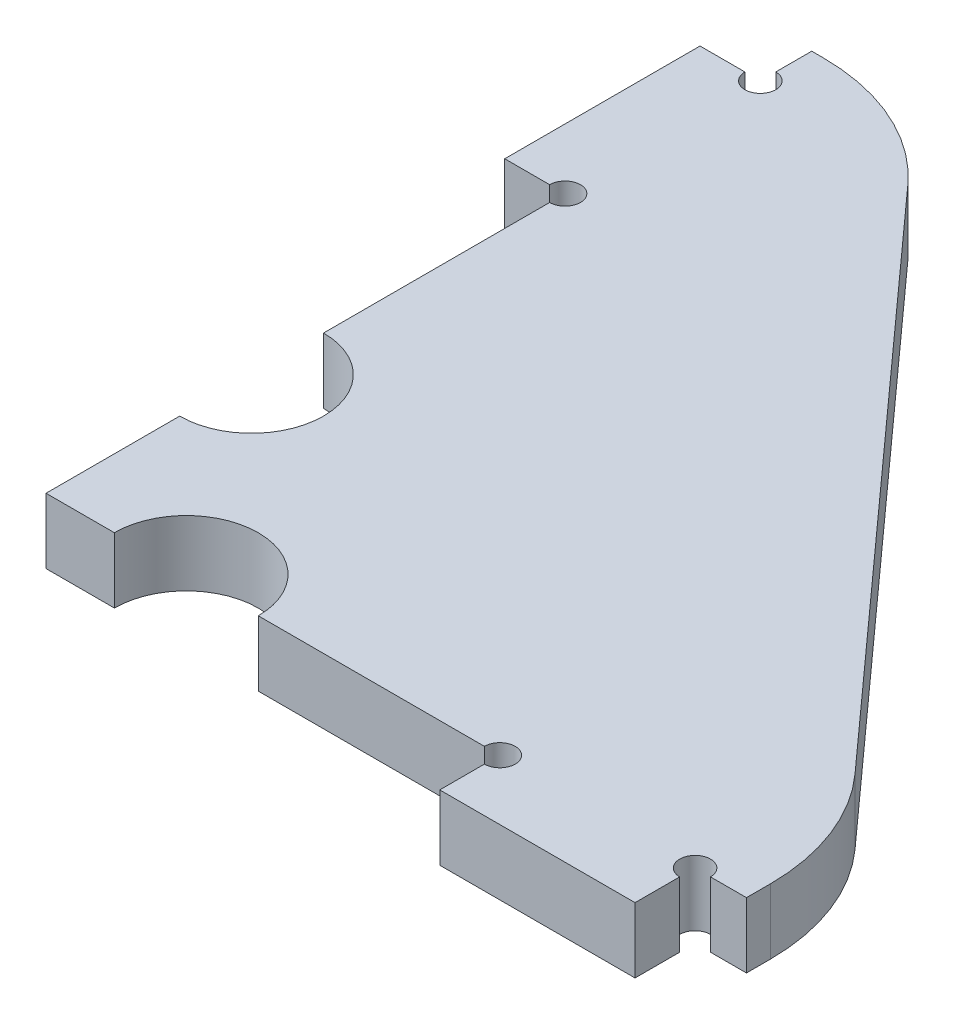
from build123d import *

# Parameters (mm, degrees)
BOSS_EXTRUDE1_DEPTH = 6.35
SKETCH3_R           = 1.5
SKETCH3_R_2         = 7
CUT_EXTRUDE1_DEPTH  = 7.35
FILLET1_R           = 20


with BuildPart() as part:
    # Sketch2 → Boss-Extrude1 (new body)
    with BuildSketch(Plane(origin=(0, 0, 0), x_dir=(1, 0, 0), z_dir=(0, 1, 0))):
        Polygon((0, 0), (44.15, 0), (44.15, -5.842), (63.15, -5.842), (63.15, 0), (68.15, 0), (68.15, 10), (10, 74.5), (0, 74.5), (0, 69.5), (-5.87, 69.5), (-5.87, 50.5), (0, 50.5), align=None)
    extrude(amount=BOSS_EXTRUDE1_DEPTH)

    # Sketch3 → Cut-Extrude1 (cut, through all)
    with BuildSketch(Plane(origin=(0, 6.35, 0), x_dir=(1, 0, 0), z_dir=(0, 1, 0))):
        with Locations((0, 69.5)):
            Circle(SKETCH3_R)
        with Locations((0, 50.5)):
            Circle(SKETCH3_R)
        with Locations((44.15, 0)):
            Circle(SKETCH3_R)
        with Locations((63.15, 0)):
            Circle(SKETCH3_R)
        with Locations((0, 20)):
            Circle(SKETCH3_R_2)
        with Locations((13.65, 0)):
            Circle(SKETCH3_R_2)
    extrude(amount=-CUT_EXTRUDE1_DEPTH, mode=Mode.SUBTRACT)

    # Fillet1
    fillet1_edges = [part.edges().sort_by_distance(p)[0] for p in [
        (10, 3.175, -74.5),
        (68.15, 3.175, -10),
    ]]
    fillet(fillet1_edges, radius=FILLET1_R)


solid = part.part
